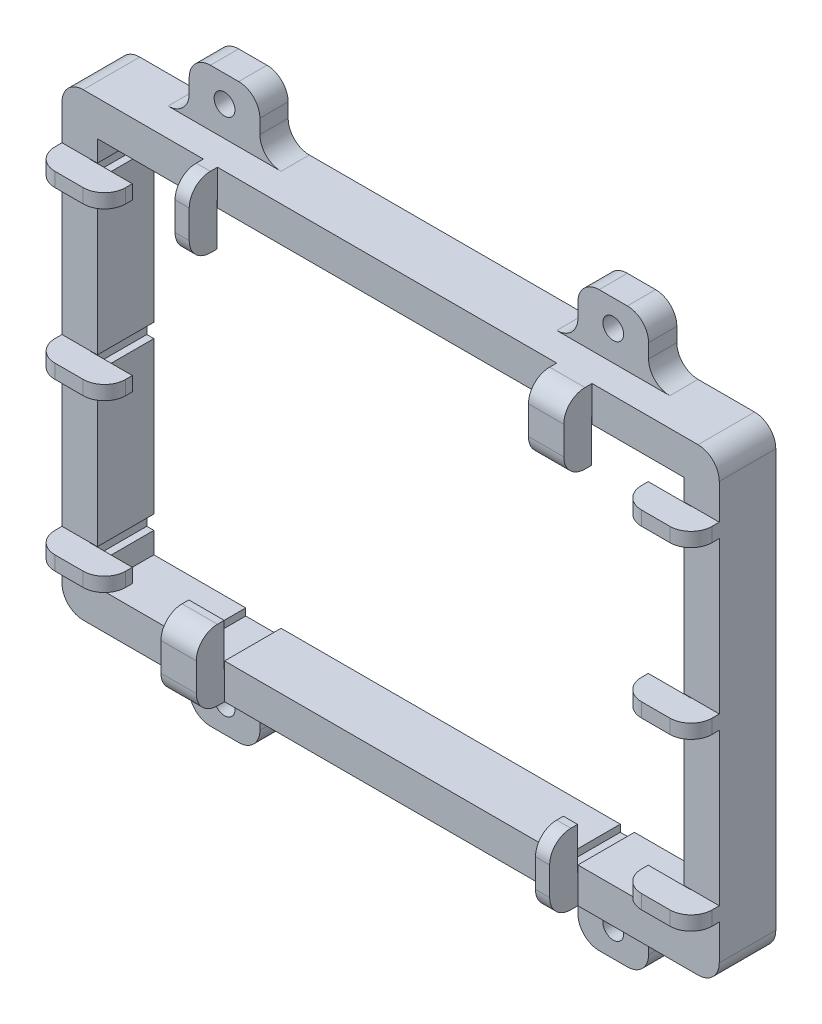
from build123d import *

# Parameters (mm, degrees)
SKETCH1_W               = 93
SKETCH1_H               = 65
SKETCH1_W_2             = 83
SKETCH1_H_2             = 55
BOSS_EXTRUDE1_DEPTH     = 8
FILLET1_R               = 3
SKETCH2_W               = 10
SKETCH2_H               = 4
BOSS_EXTRUDE6_DEPTH     = 8
FILLET3_R               = 3
SKETCH9_R               = 1.47
CUT_EXTRUDE1_DEPTH      = 5
MIRROR4_COPY_1_SKETCH_R = 1.47
MIRROR4_COPY_1_DEPTH    = 5
FILLET4_R               = 3
SKETCH10_W              = 2
SKETCH10_H              = 1
SKETCH10_W_2            = 5
CUT_EXTRUDE2_DEPTH      = 9
SKETCH11_W              = 2
SKETCH11_H              = 1
SKETCH11_W_2            = 5
CUT_EXTRUDE3_DEPTH      = 9
SKETCH12_W              = 1
SKETCH12_H              = 2
CUT_EXTRUDE4_DEPTH      = 9
SKETCH14_W              = 4
SKETCH14_H              = 2
BOSS_EXTRUDE14_DEPTH    = 4
SKETCH15_W              = 3.95
SKETCH15_H              = 2
BOSS_EXTRUDE18_DEPTH    = 6
SKETCH16_W              = 2
SKETCH16_H              = 4
SKETCH16_W_2            = 5
BOSS_EXTRUDE19_DEPTH    = 4
SKETCH17_W              = 2
SKETCH17_H              = 3.95
SKETCH17_W_2            = 5
BOSS_EXTRUDE20_DEPTH    = 6
SKETCH18_W              = 5
SKETCH18_H              = 3.95
SKETCH18_W_2            = 2
BOSS_EXTRUDE21_DEPTH    = 6
FILLET6_R               = 3


with BuildPart() as part:
    # Sketch1 → Boss-Extrude1 (new body)
    with BuildSketch(Plane.XY):
        Rectangle(SKETCH1_W, SKETCH1_H)
        Rectangle(SKETCH1_W_2, SKETCH1_H_2, mode=Mode.SUBTRACT)
    extrude(amount=BOSS_EXTRUDE1_DEPTH)

    # Fillet1
    fillet1_edges = [part.edges().sort_by_distance(p)[0] for p in [
        (-46.5, 32.5, 4),
        (46.5, 32.5, 4),
        (46.5, -32.5, 4),
        (-46.5, -32.5, 4),
    ]]
    fillet(fillet1_edges, radius=FILLET1_R)

    # Sketch2 → Boss-Extrude6 (add)
    with BuildSketch(Plane(origin=(0, 32.5, 0), x_dir=(1, 0, 0), z_dir=(0, 1, 0))):
        with Locations((-27.5, -2)):
            Rectangle(SKETCH2_W, SKETCH2_H)
        with Locations((27.5, -2)):
            Rectangle(SKETCH2_W, SKETCH2_H)
    boss_extrude6 = extrude(amount=BOSS_EXTRUDE6_DEPTH)

    # Mirror2: Boss-Extrude6 across plane
    add(boss_extrude6.mirror(Plane.ZX))

    # Fillet3
    fillet3_edges = [part.edges().sort_by_distance(p)[0] for p in [
        (32.5, -32.5, 2),
        (22.5, -32.5, 2),
        (-22.5, 32.5, 2),
        (-32.5, 32.5, 2),
        (32.5, 32.5, 2),
        (22.5, 32.5, 2),
        (-22.5, -32.5, 2),
        (-32.5, -32.5, 2),
    ]]
    fillet(fillet3_edges, radius=FILLET3_R)

    # Sketch9 → Cut-Extrude1 (cut, through all)
    with BuildSketch(Plane.XY.offset(4)):
        with Locations((27.5, -36.742693553)):
            Circle(SKETCH9_R)
    cut_extrude1 = extrude(amount=-CUT_EXTRUDE1_DEPTH, mode=Mode.SUBTRACT)

    # Mirror3: Cut-Extrude1 across plane
    add(cut_extrude1.mirror(Plane(origin=(0, 0, 0), x_dir=(0, 0, 1), z_dir=(1, 0, 0))), mode=Mode.SUBTRACT)

    # Mirror4: Cut-Extrude1 across plane
    add(cut_extrude1.mirror(Plane.ZX), mode=Mode.SUBTRACT)

    # Mirror4 copy 1 sketch → Mirror4 copy 1 (cut, through all)
    with BuildSketch(Plane(origin=(0, 0, 4), x_dir=(-1, 0, 0), z_dir=(0, 0, 1))):
        with Locations((27.5, -36.742693553)):
            Circle(MIRROR4_COPY_1_SKETCH_R)
    extrude(amount=-MIRROR4_COPY_1_DEPTH, mode=Mode.SUBTRACT)

    # Fillet4
    fillet4_edges = [part.edges().sort_by_distance(p)[0] for p in [
        (32.5, -40.5, 2),
        (22.5, -40.5, 2),
        (-22.5, 40.5, 2),
        (-32.5, 40.5, 2),
        (32.5, 40.5, 2),
        (22.5, 40.5, 2),
        (-22.5, -40.5, 2),
        (-32.5, -40.5, 2),
    ]]
    fillet(fillet4_edges, radius=FILLET4_R)

    # Sketch10 → Cut-Extrude2 (cut, through all)
    with BuildSketch(Plane(origin=(0, 0, 0), x_dir=(-1, 0, 0), z_dir=(0, 0, -1))):
        with Locations((-25.5, -28)):
            Rectangle(SKETCH10_W, SKETCH10_H)
        with Locations((26, -28)):
            Rectangle(SKETCH10_W_2, SKETCH10_H)
    extrude(amount=-CUT_EXTRUDE2_DEPTH, mode=Mode.SUBTRACT)

    # Sketch11 → Cut-Extrude3 (cut, through all)
    with BuildSketch(Plane(origin=(0, 0, 0), x_dir=(-1, 0, 0), z_dir=(0, 0, -1))):
        with Locations((25.5, 28)):
            Rectangle(SKETCH11_W, SKETCH11_H)
        with Locations((-26, 28)):
            Rectangle(SKETCH11_W_2, SKETCH11_H)
    extrude(amount=-CUT_EXTRUDE3_DEPTH, mode=Mode.SUBTRACT)

    # Sketch12 → Cut-Extrude4 (cut, through all)
    with BuildSketch(Plane(origin=(0, 0, 0), x_dir=(-1, 0, 0), z_dir=(0, 0, -1))):
        with Locations((-42, 0)):
            Rectangle(SKETCH12_W, SKETCH12_H)
        with Locations((-42, -23.5)):
            Rectangle(SKETCH12_W, SKETCH12_H)
        with Locations((-42, 23.5)):
            Rectangle(SKETCH12_W, SKETCH12_H)
    cut_extrude4 = extrude(amount=-CUT_EXTRUDE4_DEPTH, mode=Mode.SUBTRACT)

    # Mirror5: Cut-Extrude4 across plane
    add(cut_extrude4.mirror(Plane(origin=(0, 0, 0), x_dir=(0, 0, 1), z_dir=(1, 0, 0))), mode=Mode.SUBTRACT)

    # Sketch14 → Boss-Extrude14 (add)
    with BuildSketch(Plane.XY.offset(8)):
        with Locations((44.5, 23.5)):
            Rectangle(SKETCH14_W, SKETCH14_H)
        with Locations((44.5, 0)):
            Rectangle(SKETCH14_W, SKETCH14_H)
        with Locations((44.5, -23.5)):
            Rectangle(SKETCH14_W, SKETCH14_H)
    boss_extrude14 = extrude(amount=BOSS_EXTRUDE14_DEPTH)

    # Mirror6: Boss-Extrude14 across plane
    add(boss_extrude14.mirror(Plane(origin=(0, 0, 0), x_dir=(0, 0, 1), z_dir=(1, 0, 0))))

    # Sketch15 → Boss-Extrude18 (add)
    with BuildSketch(Plane.ZY.offset(-42.5)):
        with Locations((10.025, 23.5)):
            Rectangle(SKETCH15_W, SKETCH15_H)
        with Locations((10.025, 0)):
            Rectangle(SKETCH15_W, SKETCH15_H)
        with Locations((10.025, -23.5)):
            Rectangle(SKETCH15_W, SKETCH15_H)
    boss_extrude18 = extrude(amount=BOSS_EXTRUDE18_DEPTH)

    # Mirror7: Boss-Extrude18 across plane
    add(boss_extrude18.mirror(Plane(origin=(0, 0, 0), x_dir=(0, 0, 1), z_dir=(1, 0, 0))))

    # Sketch16 → Boss-Extrude19 (add)
    with BuildSketch(Plane.XY.offset(8)):
        with Locations((-25.5, 30.5)):
            Rectangle(SKETCH16_W, SKETCH16_H)
        with Locations((26, 30.5)):
            Rectangle(SKETCH16_W_2, SKETCH16_H)
        with Locations((25.5, -30.5)):
            Rectangle(SKETCH16_W, SKETCH16_H)
        with Locations((-26, -30.5)):
            Rectangle(SKETCH16_W_2, SKETCH16_H)
    extrude(amount=BOSS_EXTRUDE19_DEPTH)

    # Sketch17 → Boss-Extrude20 (add)
    with BuildSketch(Plane.XZ.offset(-28.5)):
        with Locations((-25.5, 10.025)):
            Rectangle(SKETCH17_W, SKETCH17_H)
        with Locations((26, 10.025)):
            Rectangle(SKETCH17_W_2, SKETCH17_H)
    extrude(amount=BOSS_EXTRUDE20_DEPTH)

    # Sketch18 → Boss-Extrude21 (add)
    with BuildSketch(Plane(origin=(0, -28.5, 0), x_dir=(1, 0, 0), z_dir=(0, 1, 0))):
        with Locations((-26, -10.025)):
            Rectangle(SKETCH18_W, SKETCH18_H)
        with Locations((25.5, -10.025)):
            Rectangle(SKETCH18_W_2, SKETCH18_H)
    extrude(amount=BOSS_EXTRUDE21_DEPTH)

    # Fillet6
    fillet6_edges = [part.edges().sort_by_distance(p)[0] for p in [
        (-25.5, 32.5, 12),
        (-25.5, 22.5, 12),
        (-36.5, 23.5, 12),
        (-46.5, 23.5, 12),
        (-36.5, 0, 12),
        (-46.5, 0, 12),
        (-36.5, -23.5, 12),
        (-46.5, -23.5, 12),
        (-26, -32.5, 12),
        (-26, -22.5, 12),
        (25.5, -32.5, 12),
        (25.5, -22.5, 12),
        (36.5, -23.5, 12),
        (46.5, -23.5, 12),
        (46.5, 0, 12),
        (36.5, 0, 12),
        (36.5, 23.5, 12),
        (26, 22.5, 12),
        (26, 32.5, 12),
        (46.5, 23.5, 12),
    ]]
    fillet(fillet6_edges, radius=FILLET6_R)


solid = part.part
